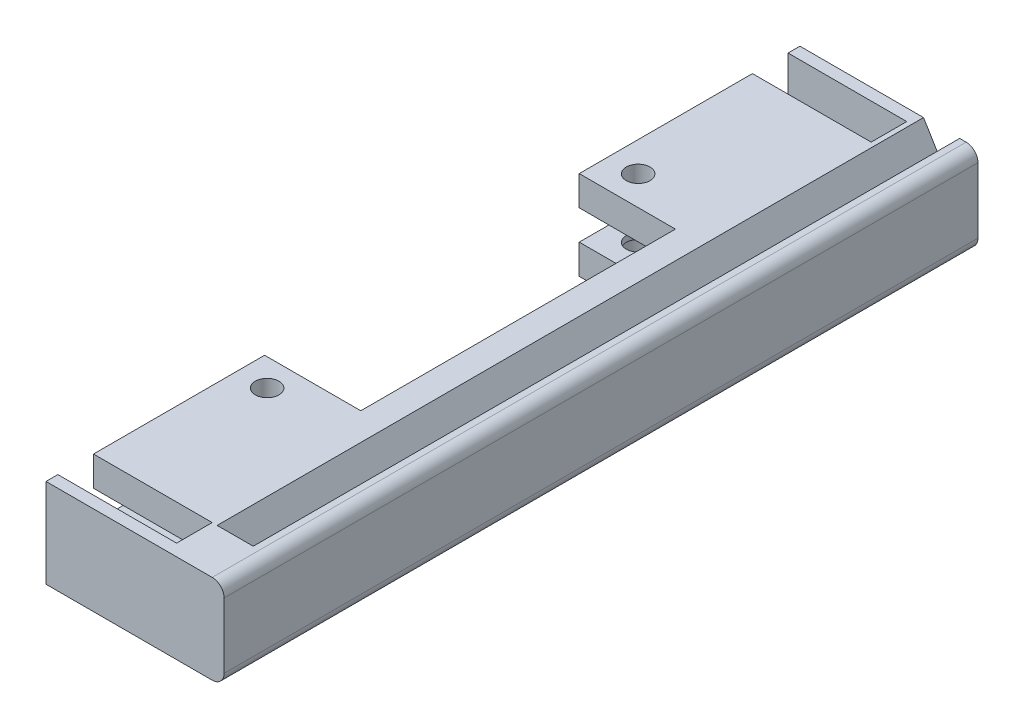
from build123d import *

# Parameters (mm, degrees)
SALIENTE_EXTRUIR1_DEPTH = 111
SALIENTE_EXTRUIR2_DEPTH = 6
CROQUIS3_W              = 20
CROQUIS3_H              = 5
SALIENTE_EXTRUIR3_DEPTH = 2
SALIENTE_EXTRUIR4_DEPTH = 6
SALIENTE_EXTRUIR5_DEPTH = 2
CROQUIS6_R              = 2
CORTAR_EXTRUIR1_DEPTH   = 41
CROQUIS7_R              = 4
CORTAR_EXTRUIR2_DEPTH   = 4
CROQUIS9_W              = 16.2
CROQUIS9_H              = 53
CORTAR_EXTRUIR4_DEPTH   = 20
CORTAR_EXTRUIR5_DEPTH   = 119


with BuildPart() as part:
    # Croquis1 → Saliente-Extruir1 (new body)
    with BuildSketch(Plane.XY):
        with BuildLine():
            Line((0, 5), (0, 0))
            Line((0, 0), (28, 0))
            ThreePointArc((28, 0), (29.414213562, 0.585786438), (30, 2))
            Line((30, 2), (30, 13))
            ThreePointArc((30, 13), (29.414213562, 14.414213562), (28, 15))
            Line((28, 15), (0, 15))
            Line((0, 15), (0, 10))
            Line((0, 10), (20, 10))
            Line((20, 10), (20, 5))
            Line((20, 5), (0, 5))
        make_face()
    extrude(amount=SALIENTE_EXTRUIR1_DEPTH)

    # Croquis2 → Saliente-Extruir2 (add)
    with BuildSketch(Plane.XY.offset(111)):
        with BuildLine():
            Line((20, 15), (20, 10))
            Line((20, 10), (20, 5))
            Line((20, 5), (0, 5))
            Line((0, 5), (0, 0))
            Line((0, 0), (28, 0))
            ThreePointArc((28, 0), (29.414213562, 0.585786438), (30, 2))
            Line((30, 2), (30, 13))
            ThreePointArc((30, 13), (29.414213562, 14.414213562), (28, 15))
            Line((28, 15), (20, 15))
        make_face()
    extrude(amount=SALIENTE_EXTRUIR2_DEPTH)

    # Croquis3 → Saliente-Extruir3 (add)
    with BuildSketch(Plane.XY.offset(117)):
        Polygon((20, 10), (20, 15), (11, 15), (0, 15), (0, 10), align=None)
        with BuildLine():
            Line((28, 15), (20, 15))
            Line((20, 15), (20, 10))
            Line((20, 10), (20, 5))
            Line((20, 5), (0, 5))
            Line((0, 5), (0, 0))
            Line((0, 0), (28, 0))
            ThreePointArc((28, 0), (29.414213562, 0.585786438), (30, 2))
            Line((30, 2), (30, 13))
            ThreePointArc((30, 13), (29.414213562, 14.414213562), (28, 15))
        make_face()
        with Locations((10, 7.5)):
            Rectangle(CROQUIS3_W, CROQUIS3_H)
    extrude(amount=SALIENTE_EXTRUIR3_DEPTH)

    # Croquis4 → Saliente-Extruir4 (add)
    with BuildSketch(Plane(origin=(0, 0, 0), x_dir=(-1, 0, 0), z_dir=(0, 0, -1))):
        with BuildLine():
            Line((-20, 5), (-20, 10))
            Line((-20, 10), (-20, 15))
            Line((-20, 15), (-28, 15))
            ThreePointArc((-28, 15), (-29.414213562, 14.414213562), (-30, 13))
            Line((-30, 13), (-30, 2))
            ThreePointArc((-30, 2), (-29.414213562, 0.585786438), (-28, 0))
            Line((-28, 0), (0, 0))
            Line((0, 0), (0, 5))
            Line((0, 5), (-20, 5))
        make_face()
    extrude(amount=SALIENTE_EXTRUIR4_DEPTH)

    # Croquis5 → Saliente-Extruir5 (add)
    with BuildSketch(Plane(origin=(0, 0, -6), x_dir=(-1, 0, 0), z_dir=(0, 0, -1))):
        with BuildLine():
            Line((0, 15), (-28, 15))
            ThreePointArc((-28, 15), (-29.414213562, 14.414213562), (-30, 13))
            Line((-30, 13), (-30, 2))
            ThreePointArc((-30, 2), (-29.414213562, 0.585786438), (-28, 0))
            Line((-28, 0), (0, 0))
            Line((0, 0), (0, 15))
        make_face()
    extrude(amount=SALIENTE_EXTRUIR5_DEPTH)

    # Croquis6 → Cortar-Extruir1 (cut)
    with BuildSketch(Plane.XZ):
        with Locations((5, 24.25)):
            Circle(CROQUIS6_R)
        with Locations((5, 86.75)):
            Circle(CROQUIS6_R)
    extrude(amount=-CORTAR_EXTRUIR1_DEPTH, mode=Mode.SUBTRACT)

    # Croquis7 → Cortar-Extruir2 (cut)
    with BuildSketch(Plane(origin=(0, 0, 0), x_dir=(-1, 0, 0), z_dir=(0, -1, 0))):
        with Locations((-5, -24.25)):
            Circle(CROQUIS7_R)
        with Locations((-5, -86.75)):
            Circle(CROQUIS7_R)
    extrude(amount=-CORTAR_EXTRUIR2_DEPTH, mode=Mode.SUBTRACT)

    # Croquis9 → Cortar-Extruir4 (cut)
    with BuildSketch(Plane.XZ):
        with Locations((8.1, 55.674909876)):
            Rectangle(CROQUIS9_W, CROQUIS9_H)
    extrude(amount=-CORTAR_EXTRUIR4_DEPTH, mode=Mode.SUBTRACT)

    # Croquis10 → Cortar-Extruir5 (cut)
    with BuildSketch(Plane(origin=(0, 0, -8), x_dir=(-1, 0, 0), z_dir=(0, 0, -1))):
        Polygon((-26.910638664, 15), (-28.420130104, 12.506734448), (-23.909345161, 9.909393396), (-20.827352116, 15), align=None)
    extrude(amount=-CORTAR_EXTRUIR5_DEPTH, mode=Mode.SUBTRACT)


solid = part.part
